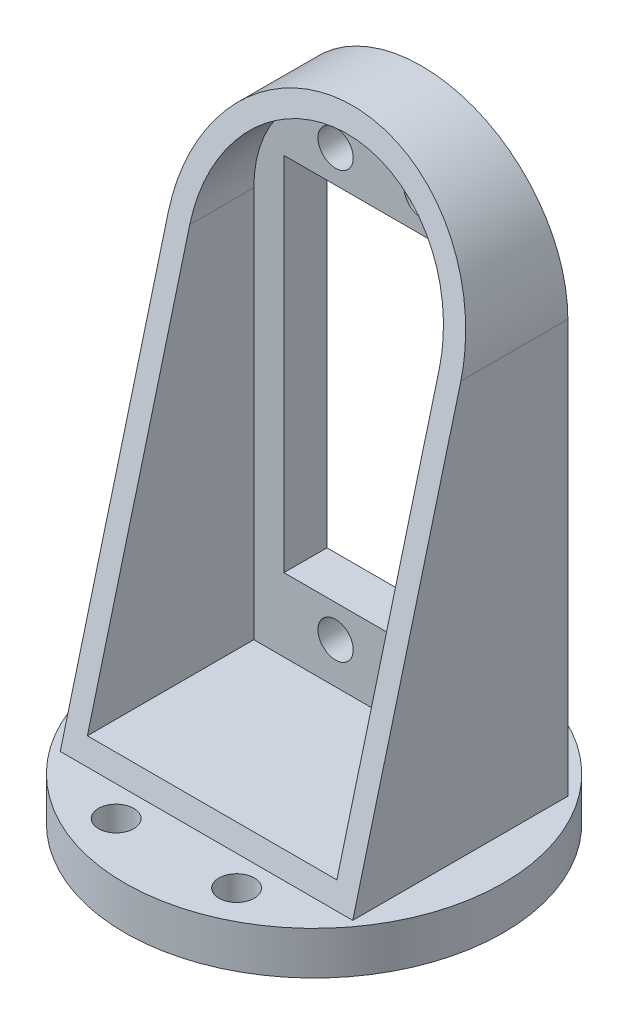
from build123d import *

# Parameters (mm, degrees)
SKETCH1_W           = 22
SKETCH1_H           = 42
SKETCH1_R           = 2.05
BOSS_EXTRUDE1_DEPTH = 5
BOSS_EXTRUDE2_DEPTH = 20
CUT_EXTRUDE1_DEPTH  = 35
SKETCH4_R           = 22
BOSS_EXTRUDE3_DEPTH = 5
SKETCH5_R           = 2.05
CUT_EXTRUDE2_DEPTH  = 5


with BuildPart() as part:
    # Sketch1 → Boss-Extrude1 (new body)
    with BuildSketch(Plane.XY):
        with BuildLine():
            Line((17, -32), (17, 16))
            ThreePointArc((17, 16), (0, 33), (-17, 16))
            Line((-17, 16), (-17, -32))
            Line((-17, -32), (17, -32))
        make_face()
        Rectangle(SKETCH1_W, SKETCH1_H, mode=Mode.SUBTRACT)
        with Locations((-5, -24.75)):
            Circle(SKETCH1_R, mode=Mode.SUBTRACT)
        with Locations((5, -24.75)):
            Circle(SKETCH1_R, mode=Mode.SUBTRACT)
        with Locations((-5, 24.75)):
            Circle(SKETCH1_R, mode=Mode.SUBTRACT)
        with Locations((5, 24.75)):
            Circle(SKETCH1_R, mode=Mode.SUBTRACT)
    extrude(amount=BOSS_EXTRUDE1_DEPTH)

    # Sketch2 → Boss-Extrude2 (add)
    with BuildSketch(Plane.XY.offset(5)):
        with BuildLine():
            Line((17, -32), (17, 16))
            ThreePointArc((17, 16), (0, 33), (-17, 16))
            Line((-17, 16), (-17, -32))
            Line((-17, -32), (17, -32))
        make_face()
        with BuildLine():
            Line((-14.5, 16), (-14.5, -29.5))
            Line((-14.5, -29.5), (14.5, -29.5))
            Line((14.5, -29.5), (14.5, 16))
            ThreePointArc((14.5, 16), (0, 30.5), (-14.5, 16))
        make_face(mode=Mode.SUBTRACT)
    extrude(amount=BOSS_EXTRUDE2_DEPTH)

    # Sketch3 → Cut-Extrude1 (cut, through all)
    with BuildSketch(Plane(origin=(17, 0, 0), x_dir=(0, 0, -1), z_dir=(1, 0, 0))):
        Polygon((-25, -32), (-8, 33), (-25, 33), align=None)
    extrude(amount=-CUT_EXTRUDE1_DEPTH, mode=Mode.SUBTRACT)

    # Sketch4 → Boss-Extrude3 (add)
    with BuildSketch(Plane.XZ.offset(32)):
        with Locations((0, 12.5)):
            Circle(SKETCH4_R)
    extrude(amount=BOSS_EXTRUDE3_DEPTH)

    # Sketch5 → Cut-Extrude2 (cut)
    with BuildSketch(Plane(origin=(0, -32, 0), x_dir=(1, 0, 0), z_dir=(0, 1, 0))):
        with Locations((0, 5)):
            Circle(SKETCH5_R)
        with Locations((-7, -28.5)):
            Circle(SKETCH5_R)
        with Locations((7, -28.5)):
            Circle(SKETCH5_R)
    extrude(amount=-CUT_EXTRUDE2_DEPTH, mode=Mode.SUBTRACT)


solid = part.part
